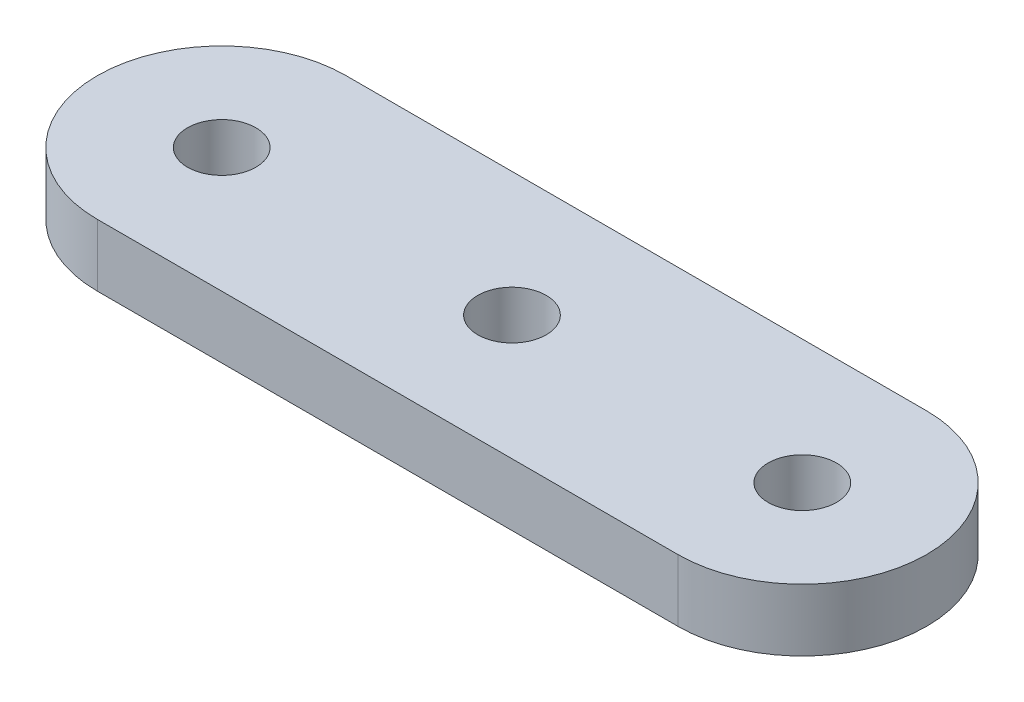
from build123d import *

# Parameters (mm, degrees)
BOSS_EXTRUDE2_DEPTH       = 3
M4X0_7_TAPPED_HOLE2_D     = 3.3
M4X0_7_TAPPED_HOLE2_DEPTH = 10.1
M4X0_7_TAPPED_HOLE2_TIP   = 0.991420021


with BuildPart() as part:
    # Sketch1 → Boss-Extrude2 (new body)
    with BuildSketch(Plane(origin=(0, 0, 0), x_dir=(1, 0, 0), z_dir=(0, 1, 0))):
        with BuildLine():
            Line((-28, 6), (0, 6))
            ThreePointArc((0, 6), (6, 0), (0, -6))
            Line((0, -6), (-28, -6))
            ThreePointArc((-28, -6), (-34, 0), (-28, 6))
        make_face()
    extrude(amount=BOSS_EXTRUDE2_DEPTH)

    # M4x0.7 Tapped Hole2
    with Locations(Plane(origin=(0, 3, 0), x_dir=(1, 0, 0), z_dir=(0, 1, 0))):
        with Locations((0, 0), (-14, 0), (-28, 0)):
            Hole(M4X0_7_TAPPED_HOLE2_D / 2, depth=M4X0_7_TAPPED_HOLE2_DEPTH)
            with Locations((0, 0, -(M4X0_7_TAPPED_HOLE2_DEPTH + M4X0_7_TAPPED_HOLE2_TIP / 2))):  # 118° drill point
                Cone(0, M4X0_7_TAPPED_HOLE2_D / 2, M4X0_7_TAPPED_HOLE2_TIP, mode=Mode.SUBTRACT)


solid = part.part
